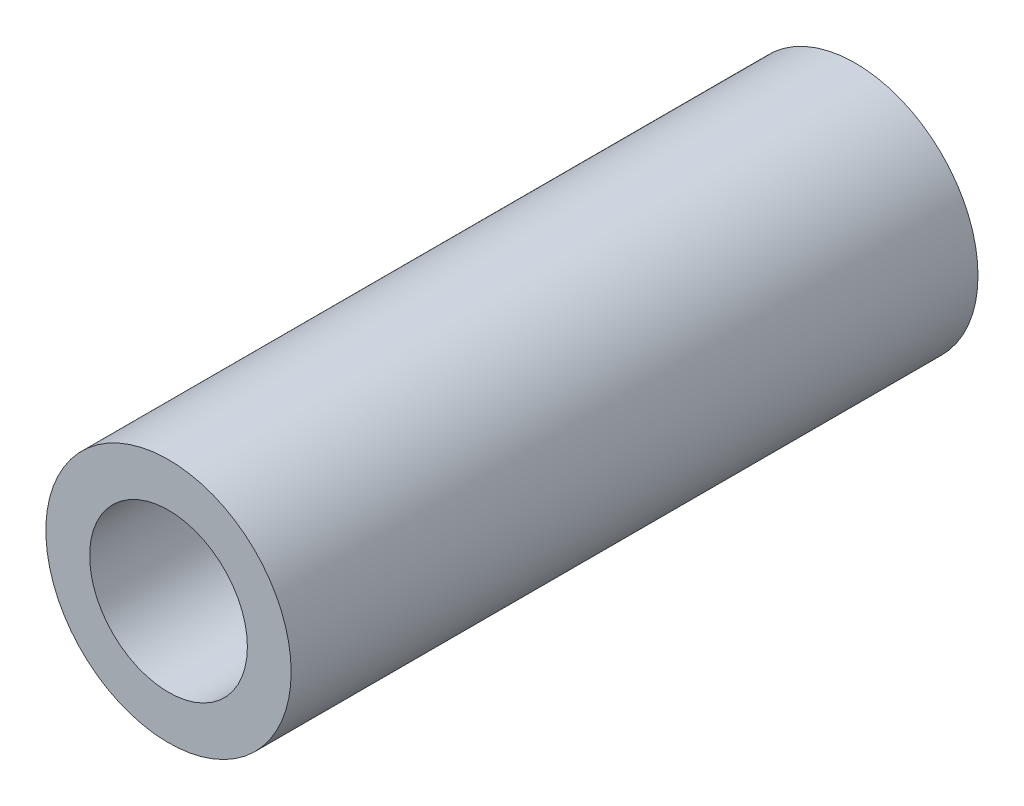
from build123d import *

# Parameters (mm, degrees)
SKETCH1_R           = 3.96875
SKETCH1_R_2         = 2.5527
BOSS_EXTRUDE1_DEPTH = 22.225


with BuildPart() as part:
    # Sketch1 → Boss-Extrude1 (new body)
    with BuildSketch(Plane.XY):
        Circle(SKETCH1_R)
        Circle(SKETCH1_R_2, mode=Mode.SUBTRACT)
    extrude(amount=BOSS_EXTRUDE1_DEPTH)


solid = part.part
